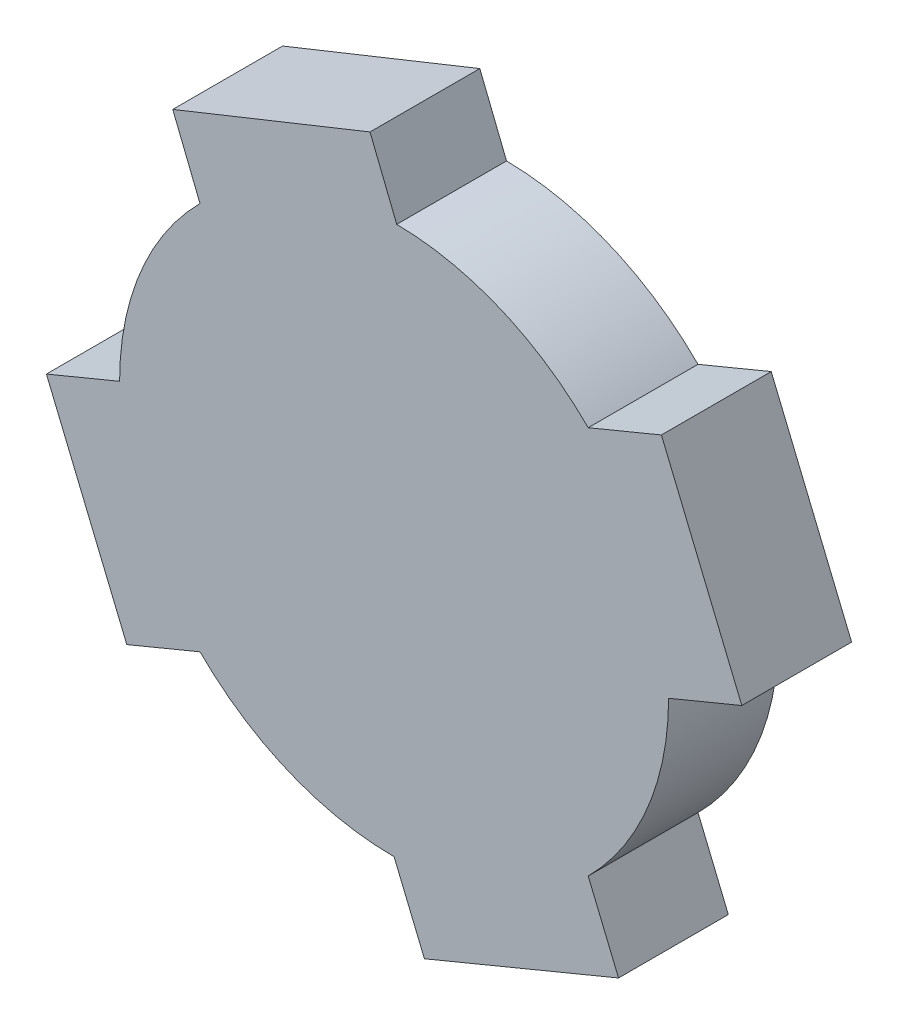
from build123d import *

# Parameters (mm, degrees)
SKETCH1_R           = 75
BOSS_EXTRUDE1_DEPTH = 30
BOSS_EXTRUDE2_DEPTH = 30


with BuildPart() as part:
    # Sketch1 → Boss-Extrude1 (new body)
    with BuildSketch(Plane.XY):
        Circle(SKETCH1_R)
    extrude(amount=BOSS_EXTRUDE1_DEPTH)

    # Sketch4 → Boss-Extrude2 (add)
    with BuildSketch(Plane.XY.offset(30)):
        with BuildLine():
            Line((61.317279836, -73.033008589), (53.033008589, -53.033008589))
            ThreePointArc((53.033008589, -53.033008589), (28.701257427, -69.290964938), (0, -75))
            Line((0, -75), (8.284271247, -95))
            Line((8.284271247, -95), (61.317279836, -73.033008589))
        make_face()
        with BuildLine():
            ThreePointArc((53.033008589, 53.033008589), (69.290964938, 28.701257427), (75, 0))
            Line((75, 0), (95, 8.284271247))
            Line((95, 8.284271247), (73.033008589, 61.317279836))
            Line((73.033008589, 61.317279836), (53.033008589, 53.033008589))
        make_face()
        with BuildLine():
            Line((-73.033008589, -61.317279836), (-53.033008589, -53.033008589))
            ThreePointArc((-53.033008589, -53.033008589), (-69.290964938, -28.701257427), (-75, 0))
            Line((-75, 0), (-95, -8.284271247))
            Line((-95, -8.284271247), (-73.033008589, -61.317279836))
        make_face()
        with BuildLine():
            ThreePointArc((0, 75), (0.359885979, 74.999136542), (0.719763671, 74.996546189))
            Line((0.719763671, 74.996546189), (-6.58190731, 93.206479314))
            Line((-6.58190731, 93.206479314), (-60.476372238, 71.596314803))
            Line((-60.476372238, 71.596314803), (-53.033008589, 53.033008589))
            ThreePointArc((-53.033008589, 53.033008589), (-28.701257427, 69.290964938), (0, 75))
        make_face()
    extrude(amount=-BOSS_EXTRUDE2_DEPTH)


solid = part.part
